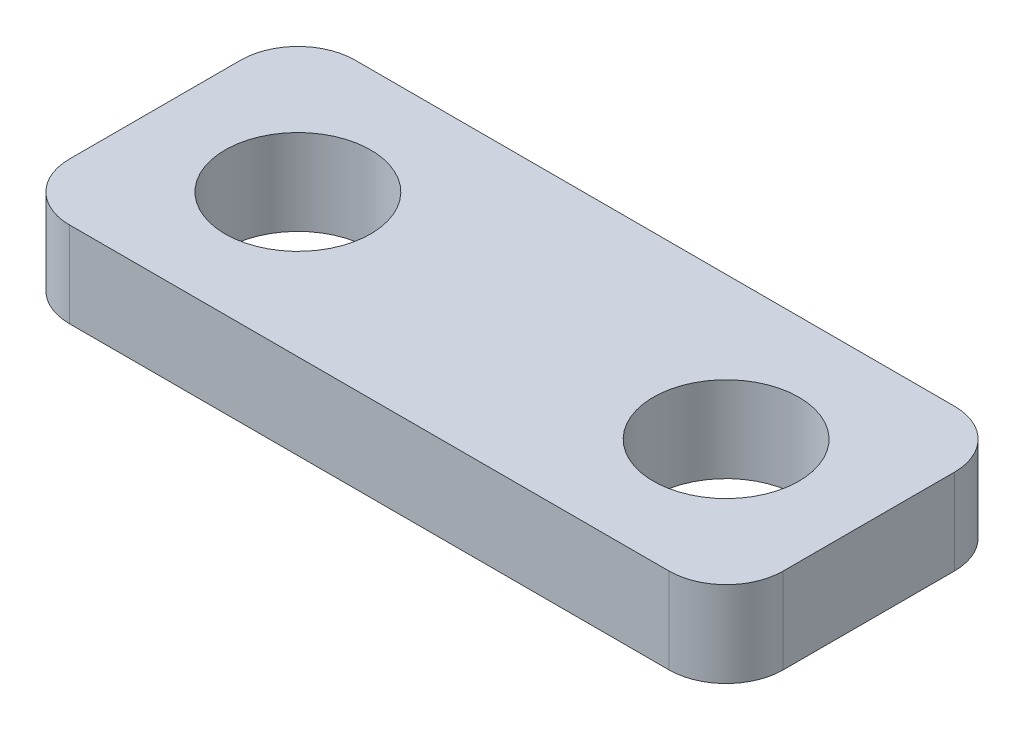
from build123d import *

# Parameters (mm, degrees)
SKETCH1_W           = 25
SKETCH1_H           = 10
SKETCH1_R           = 2.55
BOSS_EXTRUDE1_DEPTH = 3
FILLET1_R           = 2


with BuildPart() as part:
    # Sketch1 → Boss-Extrude1 (new body)
    with BuildSketch(Plane(origin=(0, 0, 0), x_dir=(1, 0, 0), z_dir=(0, 1, 0))):
        Rectangle(SKETCH1_W, SKETCH1_H)
        with Locations((-7.5, 0)):
            Circle(SKETCH1_R, mode=Mode.SUBTRACT)
        with Locations((7.5, 0)):
            Circle(SKETCH1_R, mode=Mode.SUBTRACT)
    extrude(amount=BOSS_EXTRUDE1_DEPTH)

    # Fillet1
    fillet1_edges = [part.edges().sort_by_distance(p)[0] for p in [
        (12.5, 1.5, 5),
        (-12.5, 1.5, 5),
        (-12.5, 1.5, -5),
        (12.5, 1.5, -5),
    ]]
    fillet(fillet1_edges, radius=FILLET1_R)


solid = part.part
